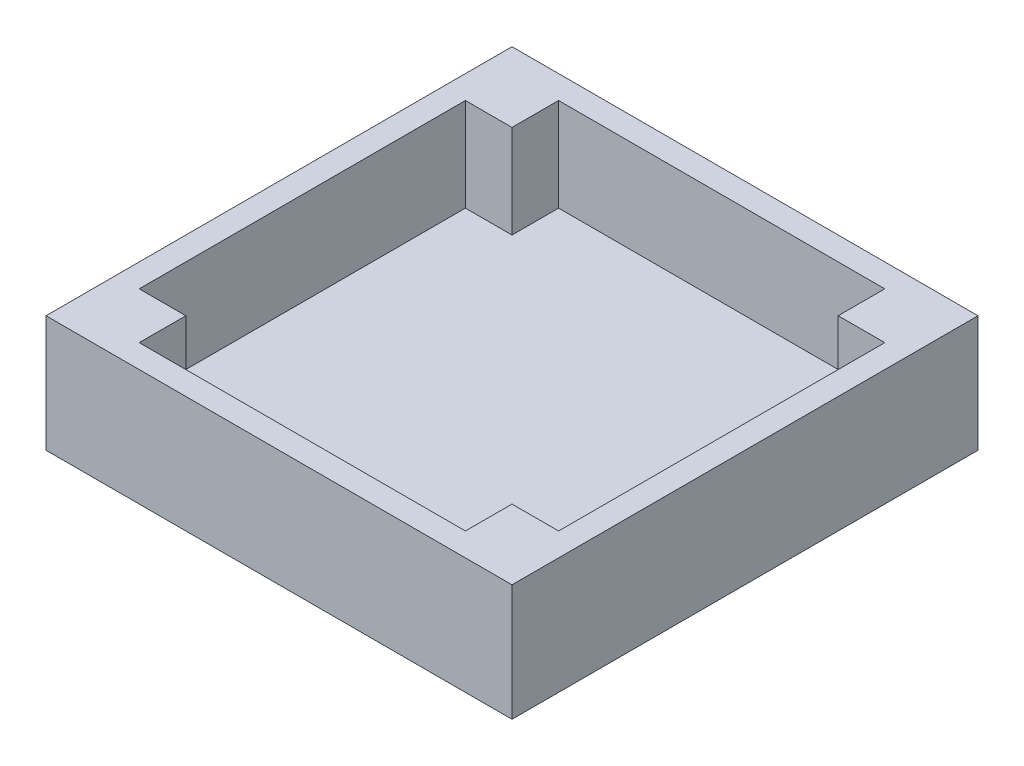
from build123d import *

# Parameters (mm, degrees)
SKETCH1_W            = 60
SKETCH1_H            = 60
BOSS_EXTRUDE1_DEPTH  = 15
SHELL1_T             = -3
SKETCH2_W            = 6
SKETCH2_H            = 6
BOSS_EXTRUDE2_DEPTH  = 12
LPATTERN1_COUNT      = 2
LPATTERN1_PITCH      = 48
LPATTERN1_COUNT_DIR2 = 2
LPATTERN1_PITCH_DIR2 = 48


with BuildPart() as part:
    # Sketch1 → Boss-Extrude1 (new body)
    with BuildSketch(Plane(origin=(0, 0, 0), x_dir=(1, 0, 0), z_dir=(0, 1, 0))):
        Rectangle(SKETCH1_W, SKETCH1_H)
    extrude(amount=BOSS_EXTRUDE1_DEPTH)

    # Shell1
    shell1_openings = [part.faces().sort_by_distance(p)[0] for p in [
        (0, 15, 0),
    ]]
    offset(amount=SHELL1_T, openings=shell1_openings, kind=Kind.INTERSECTION)

    # Sketch2 → Boss-Extrude2 (add)
    with BuildSketch(Plane(origin=(0, 3, 0), x_dir=(1, 0, 0), z_dir=(0, 1, 0))):
        with Locations((-24, 24)):
            Rectangle(SKETCH2_W, SKETCH2_H)
    boss_extrude2 = extrude(amount=BOSS_EXTRUDE2_DEPTH)

    # LPattern1: Boss-Extrude2 2 × 2
    with Locations(*[(i * LPATTERN1_PITCH, 0, j * LPATTERN1_PITCH_DIR2) for i in range(LPATTERN1_COUNT) for j in range(LPATTERN1_COUNT_DIR2) if (i, j) != (0, 0)]):
        add(boss_extrude2)


solid = part.part
